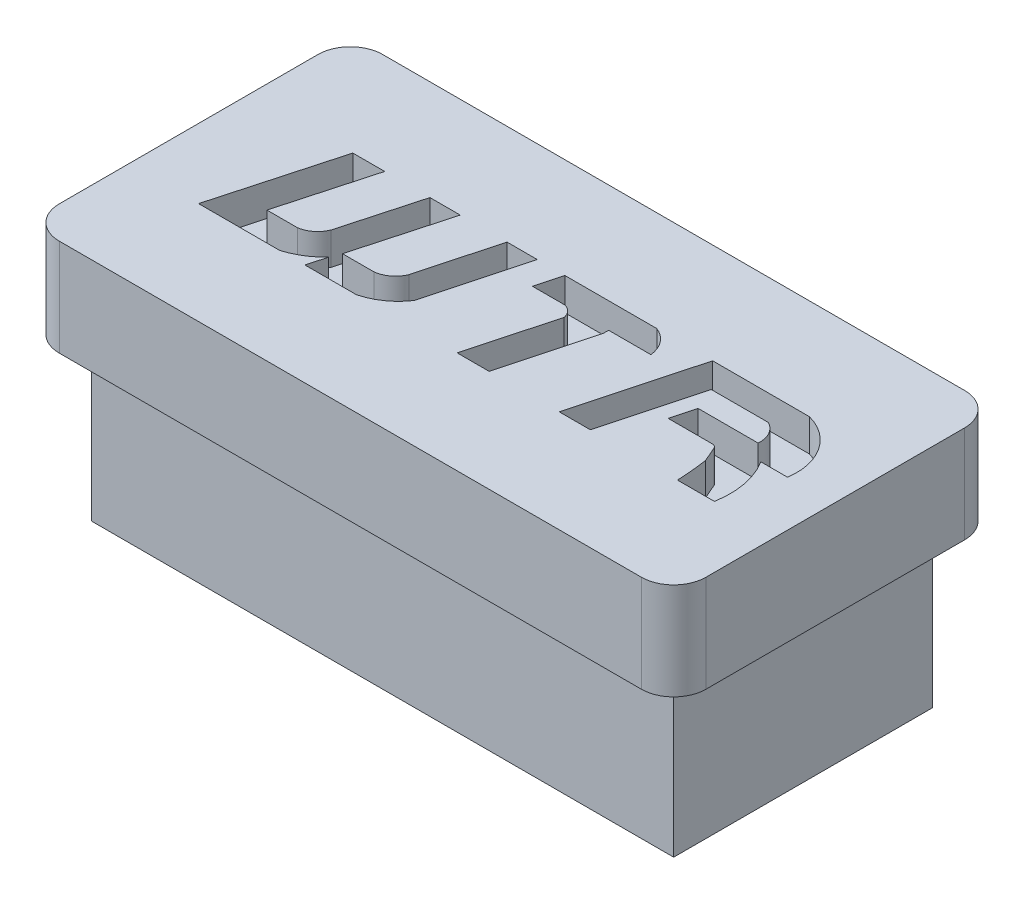
from build123d import *

# Parameters (mm, degrees)
SKETCH_1_W          = 20
SKETCH_1_H          = 10
EXTRUDE_1_DEPTH     = 3
SKETCH_2_W          = 18
SKETCH_2_H          = 8
EXTRUDE_2_DEPTH     = 5
FILLET_1_R          = 1
CUT_EXTRUDE_1_DEPTH = 1


with BuildPart() as part:
    # 草图1 → 凸台-拉伸1 (new body)
    with BuildSketch(Plane(origin=(0, 0, 0), x_dir=(1, 0, 0), z_dir=(0, 1, 0))):
        Rectangle(SKETCH_1_W, SKETCH_1_H)
    extrude(amount=EXTRUDE_1_DEPTH)

    # 草图2 → 凸台-拉伸2 (add)
    with BuildSketch(Plane.XZ):
        Rectangle(SKETCH_2_W, SKETCH_2_H)
    extrude(amount=EXTRUDE_2_DEPTH)

    # 圆角1
    fillet_1_edges = [part.edges().sort_by_distance(p)[0] for p in [
        (10, 1.5, 5),
        (-10, 1.5, 5),
        (-10, 1.5, -5),
        (10, 1.5, -5),
    ]]
    fillet(fillet_1_edges, radius=FILLET_1_R)

    # 草图5 → 切除-拉伸1 (cut)
    with BuildSketch(Plane(origin=(0, 3, 0), x_dir=(1, 0, 0), z_dir=(0, 1, 0))):
        with BuildLine():
            Line((-6.822522061, 1.898386801), (-7.8524835, -1.840514313))
            Line((-7.8524835, -1.840514313), (-5.341070676, -1.840514313))
            ThreePointArc((-5.341070676, -1.840514313), (-4.836499754, -1.613465195), (-4.406580176, -1.265166079))
            Line((-4.406580176, -1.265166079), (-4.565072331, -1.840514313))
            Line((-4.565072331, -1.840514313), (-2.97074846, -1.840514313))
            ThreePointArc((-2.97074846, -1.840514313), (-2.37793404, -1.566363371), (-1.921561777, -1.099124639))
            Line((-1.921561777, -1.099124639), (-1.115765348, 1.898386801))
            Line((-1.115765348, 1.898386801), (-2.05428464, 1.898386801))
            Line((-2.05428464, 1.898386801), (-2.697465694, -0.49420579))
            ThreePointArc((-2.697465694, -0.49420579), (-2.943387046, -0.808990294), (-3.314394459, -0.957044663))
            Line((-3.314394459, -0.957044663), (-4.284751028, -0.957044663))
            Line((-4.284751028, -0.957044663), (-3.498160474, 1.898386801))
            Line((-3.498160474, 1.898386801), (-4.436679766, 1.898386801))
            Line((-4.436679766, 1.898386801), (-5.09577131, -0.49420579))
            ThreePointArc((-5.09577131, -0.49420579), (-5.322706757, -0.801733869), (-5.671922697, -0.957044663))
            Line((-5.671922697, -0.957044663), (-6.621478358, -0.957044663))
            Line((-6.621478358, -0.957044663), (-5.834887804, 1.898386801))
            Line((-5.834887804, 1.898386801), (-6.822522061, 1.898386801))
        make_face()
        with BuildLine():
            Line((-0.475088321, 1.107844934), (-0.262573431, 1.898386801))
            Line((-0.262573431, 1.898386801), (2.578248558, 1.898386801))
            ThreePointArc((2.578248558, 1.898386801), (2.994614434, 1.589766994), (3.185291795, 1.107844934))
            Line((3.185291795, 1.107844934), (1.880601852, 1.107844934))
            Line((1.880601852, 1.107844934), (1.880601852, 0.939138509))
            Line((1.880601852, 0.939138509), (1.13337057, -1.840514313))
            Line((1.13337057, -1.840514313), (0.14506348, -1.840514313))
            Line((0.14506348, -1.840514313), (0.846029375, 0.767034213))
            ThreePointArc((0.846029375, 0.767034213), (0.732607363, 0.989649387), (0.512489482, 1.107844934))
            Line((0.512489482, 1.107844934), (-0.475088321, 1.107844934))
        make_face()
        with BuildLine():
            Line((4.307003713, 1.898386801), (3.301905576, -1.840514313))
            Line((3.301905576, -1.840514313), (4.261825646, -1.840514313))
            Line((4.261825646, -1.840514313), (5.054408893, 1.107844934))
            Line((5.054408893, 1.107844934), (6.821228484, 1.107844934))
            ThreePointArc((6.821228484, 1.107844934), (7.123952053, 0.812017942), (7.213476308, 0.398326541))
            Line((7.213476308, 0.398326541), (5.355376817, 0.398326541))
            Line((5.355376817, 0.398326541), (5.159115285, -0.331753873))
            Line((5.159115285, -0.331753873), (6.505334941, -0.331753873))
            ThreePointArc((6.505334941, -0.331753873), (6.603923501, -0.353634595), (6.670750012, -0.42934911))
            Line((6.670750012, -0.42934911), (6.864004091, -0.875832672))
            ThreePointArc((6.864004091, -0.875832672), (6.92537385, -1.35673953), (6.9569905, -1.840514313))
            Line((6.9569905, -1.840514313), (8.099394952, -1.840514313))
            ThreePointArc((8.099394952, -1.840514313), (8.094576963, -0.91999968), (7.760433181, -0.062259431))
            Line((7.760433181, -0.062259431), (8.581825646, -0.062259431))
            ThreePointArc((8.581825646, -0.062259431), (8.316855125, 1.163927045), (7.299844055, 1.898386801))
            Line((7.299844055, 1.898386801), (4.307003713, 1.898386801))
        make_face()
    extrude(amount=-CUT_EXTRUDE_1_DEPTH, mode=Mode.SUBTRACT)


solid = part.part
